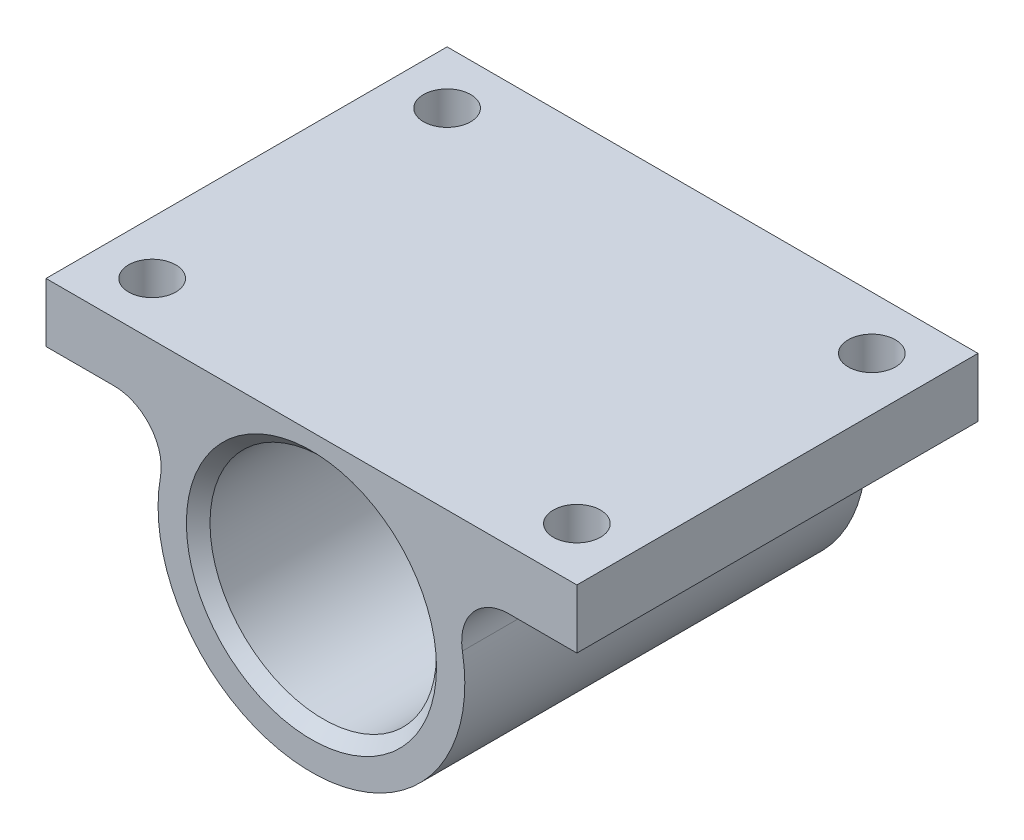
from build123d import *

# Parameters (mm, degrees)
SKETCH1_R           = 9.6
BOSS_EXTRUDE1_DEPTH = 34
SKETCH2_R           = 2
CUT_EXTRUDE1_DEPTH  = 34
SKETCH3_R           = 4
CUT_EXTRUDE2_DEPTH  = 34
SKETCH4_R           = 9.6
SKETCH4_R_2         = 8.5
BOSS_EXTRUDE2_DEPTH = 2
CHAMFER1_SIZE       = 1


with BuildPart() as part:
    # Sketch1 → Boss-Extrude1 (new body)
    with BuildSketch(Plane.XY):
        with BuildLine():
            Line((16.733200531, 7), (22.5, 7))
            Line((22.5, 7), (22.5, 12))
            Line((22.5, 12), (-22.5, 12))
            Line((-22.5, 12), (-22.5, 7))
            Line((-22.5, 7), (-16.733200531, 7))
            ThreePointArc((-16.733200531, 7), (-13.665340575, 5.566755792), (-12.795976876, 2.294117647))
            ThreePointArc((-12.795976876, 2.294117647), (0, -13), (12.795976876, 2.294117647))
            ThreePointArc((12.795976876, 2.294117647), (13.665340575, 5.566755792), (16.733200531, 7))
        make_face()
        Circle(SKETCH1_R, mode=Mode.SUBTRACT)
    extrude(amount=BOSS_EXTRUDE1_DEPTH)

    # Sketch2 → Cut-Extrude1 (cut)
    with BuildSketch(Plane(origin=(0, 12, 0), x_dir=(1, 0, 0), z_dir=(0, 1, 0))):
        with Locations(Location((-18, -29.5, 0), (0, 0, 270))):  # turned: the seam where the file's is
            Circle(SKETCH2_R)
        with Locations(Location((18, -29.5, 0), (0, 0, 270))):  # turned: the seam where the file's is
            Circle(SKETCH2_R)
        with Locations(Location((18, -4.5, 0), (0, 0, 270))):  # turned: the seam where the file's is
            Circle(SKETCH2_R)
        with Locations(Location((-18, -4.5, 0), (0, 0, 270))):  # turned: the seam where the file's is
            Circle(SKETCH2_R)
    extrude(amount=-CUT_EXTRUDE1_DEPTH, mode=Mode.SUBTRACT)

    # Sketch3 → Cut-Extrude2 (cut)
    with BuildSketch(Plane.XZ.offset(-7)):
        with Locations((-18, 29.5)):
            Circle(SKETCH3_R)
        with Locations((-18, 4.5)):
            Circle(SKETCH3_R)
        with Locations((18, 4.5)):
            Circle(SKETCH3_R)
        with Locations((18, 29.5)):
            Circle(SKETCH3_R)
    extrude(amount=CUT_EXTRUDE2_DEPTH, mode=Mode.SUBTRACT)

    # Sketch4 → Boss-Extrude2 (add)
    with BuildSketch(Plane(origin=(0, 0, 0), x_dir=(-1, 0, 0), z_dir=(0, 0, -1))):
        Circle(SKETCH4_R)
        Circle(SKETCH4_R_2, mode=Mode.SUBTRACT)
    extrude(amount=-BOSS_EXTRUDE2_DEPTH)

    # Chamfer1
    chamfer1_edges = [part.edges().sort_by_distance(p)[0] for p in [
        (-9.6, 0, 34),
    ]]
    chamfer(chamfer1_edges, length=CHAMFER1_SIZE)


solid = part.part
